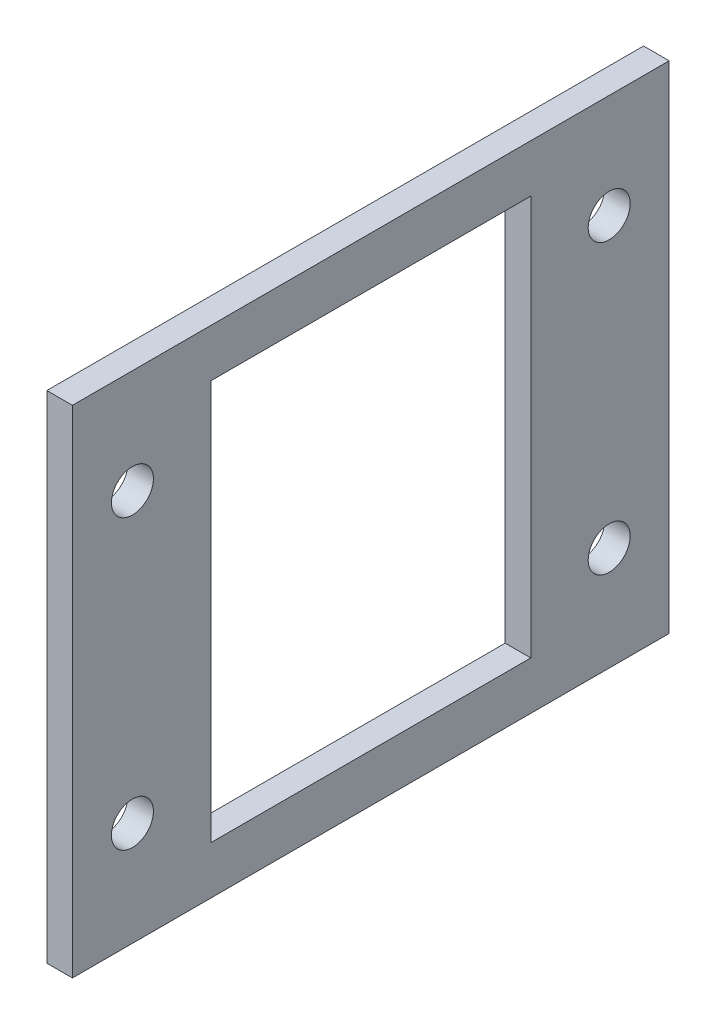
from build123d import *

# Parameters (mm, degrees)
SKETCH1_W           = 74.6
SKETCH1_H           = 62
BOSS_EXTRUDE1_DEPTH = 3.2
CUT_EXTRUDE1_REACH  = 5.2
SKETCH2_W           = 40
SKETCH2_H           = 50
CUT_EXTRUDE2_REACH  = 5.2
SKETCH3_R           = 2.625


with BuildPart() as part:
    # Sketch1 → Boss-Extrude1 (new body)
    with BuildSketch(Plane(origin=(0, 0, 0), x_dir=(0, 0, -1), z_dir=(1, 0, 0))):
        with Locations((37.3, 31)):
            Rectangle(SKETCH1_W, SKETCH1_H)
    extrude(amount=BOSS_EXTRUDE1_DEPTH)

    # Sketch2 → Cut-Extrude1 (cut, up to next)
    with BuildSketch(Plane(origin=(3.2, 0, 0), x_dir=(0, 0, -1), z_dir=(1, 0, 0)), mode=Mode.PRIVATE) as cut_extrude1_sk1:
        with Locations((37.3, 31)):
            Rectangle(SKETCH2_W, SKETCH2_H)
    cut_extrude1_tool1 = extrude(cut_extrude1_sk1.sketch, amount=-CUT_EXTRUDE1_REACH, mode=Mode.PRIVATE) & part.part
    add(cut_extrude1_tool1.solids().sort_by_distance((3.2, 31, -37.3))[0], mode=Mode.SUBTRACT)

    # Sketch3 → Cut-Extrude2 (cut, up to next)
    with BuildSketch(Plane.ZY, mode=Mode.PRIVATE) as cut_extrude2_sk1:
        with Locations((-67.1, 13)):
            Circle(SKETCH3_R)
    cut_extrude2_tool1 = extrude(cut_extrude2_sk1.sketch, amount=-CUT_EXTRUDE2_REACH, mode=Mode.PRIVATE) & part.part
    add(cut_extrude2_tool1.solids().sort_by_distance((0, 13, -67.1))[0], mode=Mode.SUBTRACT)
    # Sketch3 → Cut-Extrude2 (cut, up to next)
    with BuildSketch(Plane.ZY, mode=Mode.PRIVATE) as cut_extrude2_sk2:
        with Locations((-67.1, 49)):
            Circle(SKETCH3_R)
    cut_extrude2_tool2 = extrude(cut_extrude2_sk2.sketch, amount=-CUT_EXTRUDE2_REACH, mode=Mode.PRIVATE) & part.part
    add(cut_extrude2_tool2.solids().sort_by_distance((0, 49, -67.1))[0], mode=Mode.SUBTRACT)
    # Sketch3 → Cut-Extrude2 (cut, up to next)
    with BuildSketch(Plane.ZY, mode=Mode.PRIVATE) as cut_extrude2_sk3:
        with Locations((-7.5, 49)):
            Circle(SKETCH3_R)
    cut_extrude2_tool3 = extrude(cut_extrude2_sk3.sketch, amount=-CUT_EXTRUDE2_REACH, mode=Mode.PRIVATE) & part.part
    add(cut_extrude2_tool3.solids().sort_by_distance((0, 49, -7.5))[0], mode=Mode.SUBTRACT)
    # Sketch3 → Cut-Extrude2 (cut, up to next)
    with BuildSketch(Plane.ZY, mode=Mode.PRIVATE) as cut_extrude2_sk4:
        with Locations((-7.5, 13)):
            Circle(SKETCH3_R)
    cut_extrude2_tool4 = extrude(cut_extrude2_sk4.sketch, amount=-CUT_EXTRUDE2_REACH, mode=Mode.PRIVATE) & part.part
    add(cut_extrude2_tool4.solids().sort_by_distance((0, 13, -7.5))[0], mode=Mode.SUBTRACT)


solid = part.part
